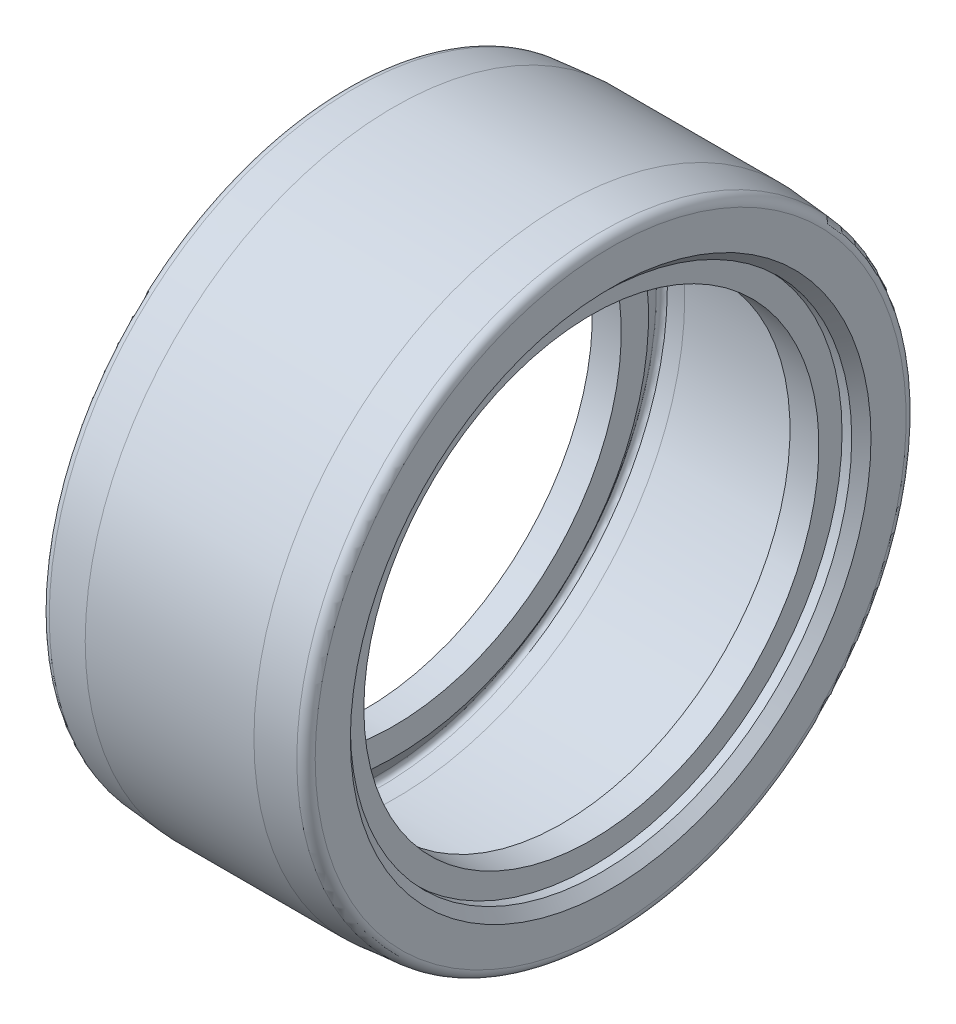
from build123d import *


with BuildPart() as part:
    # Esquisse1 → Révolution1 (revolve)
    with BuildSketch(Plane.XY):
        with BuildLine():
            Line((-2.5, 30.646225508), (-2.5, 27))
            Line((-2.5, 27), (-1.5, 26))
            Line((-1.5, 26), (-0.5, 26))
            Line((-0.5, 26), (-0.5, 23.6))
            Line((-0.5, 23.6), (2.5, 23.6))
            Line((2.5, 23.6), (2.5, 26.429629983))
            Line((2.5, 26.429629983), (0.646082423, 29.077298676))
            ThreePointArc((0.646082423, 29.077298676), (0.602504551, 29.575396025), (1.012080574, 29.862184243))
            Line((1.012080574, 29.862184243), (2.674311485, 30.007610604))
            Line((2.674311485, 30.007610604), (19.825688515, 30.007610604))
            Line((19.825688515, 30.007610604), (21.487919426, 29.862184243))
            ThreePointArc((21.487919426, 29.862184243), (21.897495449, 29.575396025), (21.853917577, 29.077298676))
            Line((21.853917577, 29.077298676), (20, 26.429629983))
            Line((20, 26.429629983), (20, 23.6))
            Line((20, 23.6), (23, 23.6))
            Line((23, 23.6), (23, 26))
            Line((23, 26), (24, 26))
            Line((24, 26), (25, 27))
            Line((25, 27), (25, 30.646225508))
            ThreePointArc((25, 30.646225508), (24.737277337, 31.321815716), (24.087155743, 31.642420206))
            Line((24.087155743, 31.642420206), (20, 32))
            Line((20, 32), (2.5, 32))
            Line((2.5, 32), (-1.587155743, 31.642420206))
            ThreePointArc((-1.587155743, 31.642420206), (-2.237277337, 31.321815716), (-2.5, 30.646225508))
        make_face()
    revolve(axis=Axis((10, 0, 0), (1, 0, 0)))


solid = part.part
